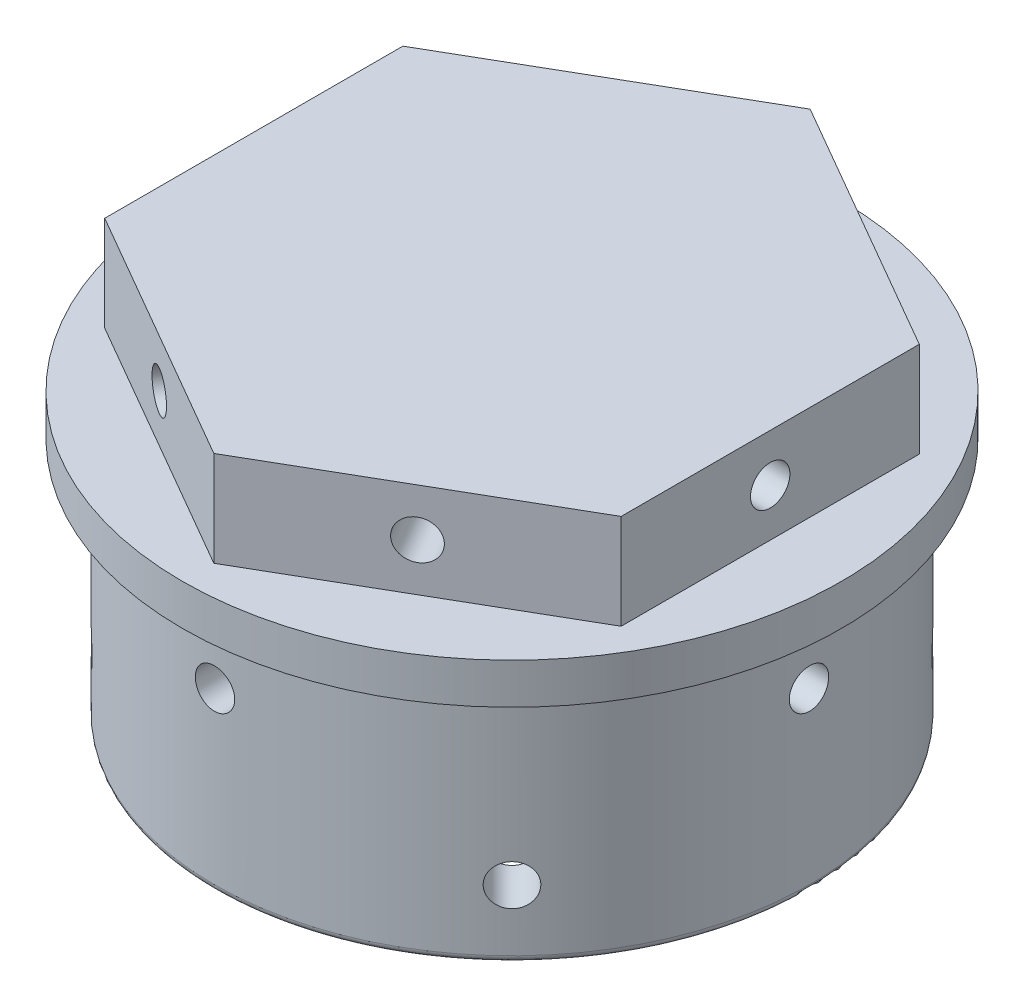
from build123d import *

# Parameters (mm, degrees)
SKETCH_1_R                = 19
SKETCH_1_R_2              = 1.45
SKETCH_1_R_3              = 2
EXTRUDE_1_DEPTH           = 12
SKETCH_2_R                = 1.45
SKETCH_2_R_2              = 2
EXTRUDE_2_DEPTH           = 7
SKETCH_3_R                = 1.45
CUT_EXTRUDE_1_DEPTH       = 48.5
SKETCH_4_R                = 1.45
CUT_EXTRUDE_2_DEPTH       = 48.5
SKETCH_5_R                = 1.45
CUT_EXTRUDE_3_DEPTH       = 39
SKETCH_8_R                = 24
CUT_EXTRUDE_6_DEPTH       = 5
SKETCH_10_R               = 24.25
EXTRUDE_3_DEPTH           = 3
SKETCH_11_R               = 21.9
EXTRUDE_4_DEPTH           = 18
CUT_EXTRUDE_7_DEPTH       = 18
SKETCH_13_R               = 1.45
CUT_EXTRUDE_8_DEPTH       = 43.25
CUT_EXTRUDE_8_DEPTH_BACK  = 7.25
SKETCH_14_R               = 1.45
CUT_EXTRUDE_9_DEPTH       = 53.294678888
CUT_EXTRUDE_9_DEPTH_BACK  = 17.294678888
SKETCH_15_R               = 1.45
CUT_EXTRUDE_10_DEPTH      = 43.25
CUT_EXTRUDE_10_DEPTH_BACK = 7.25
SKETCH_16_R               = 1.5
CUT_EXTRUDE_11_DEPTH      = 53.294678888
CUT_EXTRUDE_11_DEPTH_BACK = 17.294678888
FILLET_1_R                = 0.5
FILLET_2_R                = 2
SKETCH_17_R               = 1.45
SKETCH_17_R_2             = 2
SKETCH_17_R_3             = 2.272593427
EXTRUDE_5_DEPTH           = 9


with BuildPart() as part:
    # 草图1 → 凸台-拉伸1 (new body)
    with BuildSketch(Plane(origin=(0, 0, 0), x_dir=(1, 0, 0), z_dir=(0, 1, 0))):
        Circle(SKETCH_1_R)
        with Locations((0, 13.5)):
            Circle(SKETCH_1_R_2, mode=Mode.SUBTRACT)
        with Locations((-11.691342951, -6.75)):
            Circle(SKETCH_1_R_2, mode=Mode.SUBTRACT)
        with Locations((11.691342951, -6.75)):
            Circle(SKETCH_1_R_2, mode=Mode.SUBTRACT)
        with Locations((-10.522208656, 6.075)):
            Circle(SKETCH_1_R_3, mode=Mode.SUBTRACT)
        with Locations((0, -12.15)):
            Circle(SKETCH_1_R_3, mode=Mode.SUBTRACT)
        with Locations((10.522208656, 6.075)):
            Circle(SKETCH_1_R_3, mode=Mode.SUBTRACT)
    extrude(amount=EXTRUDE_1_DEPTH)

    # 草图2 → 凸台-拉伸2 (add)
    with BuildSketch(Plane(origin=(0, 12, 0), x_dir=(1, 0, 0), z_dir=(0, 1, 0))):
        Polygon((0, 21.939310229), (-19, 10.969655115), (-19, -10.969655115), (0, -21.939310229), (19, -10.969655115), (19, 10.969655115), align=None)
        with Locations((0, 13.5)):
            Circle(SKETCH_2_R, mode=Mode.SUBTRACT)
        with Locations((-10.522208656, 6.075)):
            Circle(SKETCH_2_R_2, mode=Mode.SUBTRACT)
        with Locations((10.522208656, 6.075)):
            Circle(SKETCH_2_R_2, mode=Mode.SUBTRACT)
        with Locations((-11.691342951, -6.75)):
            Circle(SKETCH_2_R, mode=Mode.SUBTRACT)
        with Locations((0, -12.15)):
            Circle(SKETCH_2_R_2, mode=Mode.SUBTRACT)
        with Locations((11.691342951, -6.75)):
            Circle(SKETCH_2_R, mode=Mode.SUBTRACT)
    extrude(amount=-EXTRUDE_2_DEPTH)

    # 草图3 → 切除-拉伸1 (cut, through all)
    with BuildSketch(Plane(origin=(9.5, 0, 16.454482672), x_dir=(0.866025404, 0, -0.5), z_dir=(0.5, 0, 0.866025404))):
        with Locations((0, 8.5)):
            Circle(SKETCH_3_R)
    extrude(amount=-CUT_EXTRUDE_1_DEPTH, mode=Mode.SUBTRACT)

    # 草图4 → 切除-拉伸2 (cut, through all)
    with BuildSketch(Plane(origin=(-9.5, 0, 16.454482672), x_dir=(0.866025404, 0, 0.5), z_dir=(-0.5, 0, 0.866025404))):
        with Locations((0, 8.5)):
            Circle(SKETCH_4_R)
    extrude(amount=-CUT_EXTRUDE_2_DEPTH, mode=Mode.SUBTRACT)

    # 草图5 → 切除-拉伸3 (cut, through all)
    with BuildSketch(Plane.ZY.offset(19)):
        with Locations((0, 8.5)):
            Circle(SKETCH_5_R)
    extrude(amount=-CUT_EXTRUDE_3_DEPTH, mode=Mode.SUBTRACT)

    # 草图8 → 切除-拉伸6 (cut)
    with BuildSketch(Plane.XZ):
        Circle(SKETCH_8_R)
    extrude(amount=-CUT_EXTRUDE_6_DEPTH, mode=Mode.SUBTRACT)

    # 草图10 → 凸台-拉伸3 (add)
    with BuildSketch(Plane.XZ.offset(-5)):
        Circle(SKETCH_10_R)
    extrude(amount=EXTRUDE_3_DEPTH)

    # 草图11 → 凸台-拉伸4 (add)
    with BuildSketch(Plane.XZ.offset(-2)):
        Circle(SKETCH_11_R)
    extrude(amount=EXTRUDE_4_DEPTH)

    # 草图12 → 切除-拉伸7 (cut)
    with BuildSketch(Plane.XZ.offset(16)):
        with BuildLine():
            Line((-15.656854249, -9.798989873), (-9.798989873, -15.656854249))
            ThreePointArc((-9.798989873, -15.656854249), (-7.203603083, -17.39103626), (-4.142135624, -18))
            Line((-4.142135624, -18), (4.142135624, -18))
            ThreePointArc((4.142135624, -18), (7.203603083, -17.39103626), (9.798989873, -15.656854249))
            Line((9.798989873, -15.656854249), (15.656854249, -9.798989873))
            ThreePointArc((15.656854249, -9.798989873), (17.39103626, -7.203603083), (18, -4.142135624))
            Line((18, -4.142135624), (18, 4.142135624))
            ThreePointArc((18, 4.142135624), (17.39103626, 7.203603083), (15.656854249, 9.798989873))
            Line((15.656854249, 9.798989873), (9.798989873, 15.656854249))
            ThreePointArc((9.798989873, 15.656854249), (7.203603083, 17.39103626), (4.142135624, 18))
            Line((4.142135624, 18), (-4.142135624, 18))
            ThreePointArc((-4.142135624, 18), (-7.203603083, 17.39103626), (-9.798989873, 15.656854249))
            Line((-9.798989873, 15.656854249), (-15.656854249, 9.798989873))
            ThreePointArc((-15.656854249, 9.798989873), (-17.39103626, 7.203603083), (-18, 4.142135624))
            Line((-18, 4.142135624), (-18, -4.142135624))
            ThreePointArc((-18, -4.142135624), (-17.39103626, -7.203603083), (-15.656854249, -9.798989873))
        make_face()
    extrude(amount=-CUT_EXTRUDE_7_DEPTH, mode=Mode.SUBTRACT)

    # 草图13 → 切除-拉伸8 (cut, two sides)
    with BuildSketch(Plane.ZY.offset(-18)) as cut_extrude_8_sk:
        with Locations((0, -3)):
            Circle(SKETCH_13_R)
    extrude(amount=CUT_EXTRUDE_8_DEPTH, mode=Mode.SUBTRACT)
    extrude(cut_extrude_8_sk.sketch, amount=-CUT_EXTRUDE_8_DEPTH_BACK, mode=Mode.SUBTRACT)

    # 草图14 → 切除-拉伸9 (cut, two sides)
    with BuildSketch(Plane(origin=(12.727922061, 0, -12.727922061), x_dir=(0.707106781, 0, 0.707106781), z_dir=(-0.707106781, 0, 0.707106781))) as cut_extrude_9_sk:
        with Locations((0, -11)):
            Circle(SKETCH_14_R)
    extrude(amount=CUT_EXTRUDE_9_DEPTH, mode=Mode.SUBTRACT)
    extrude(cut_extrude_9_sk.sketch, amount=-CUT_EXTRUDE_9_DEPTH_BACK, mode=Mode.SUBTRACT)

    # 草图15 → 切除-拉伸10 (cut, two sides)
    with BuildSketch(Plane.XY.offset(-18)) as cut_extrude_10_sk:
        with Locations((0, -3)):
            Circle(SKETCH_15_R)
    extrude(amount=CUT_EXTRUDE_10_DEPTH, mode=Mode.SUBTRACT)
    extrude(cut_extrude_10_sk.sketch, amount=-CUT_EXTRUDE_10_DEPTH_BACK, mode=Mode.SUBTRACT)

    # 草图16 → 切除-拉伸11 (cut, two sides)
    with BuildSketch(Plane(origin=(-12.727922061, 0, -12.727922061), x_dir=(0.707106781, 0, -0.707106781), z_dir=(0.707106781, 0, 0.707106781))) as cut_extrude_11_sk:
        with Locations((0, -11)):
            Circle(SKETCH_16_R)
    extrude(amount=CUT_EXTRUDE_11_DEPTH, mode=Mode.SUBTRACT)
    extrude(cut_extrude_11_sk.sketch, amount=-CUT_EXTRUDE_11_DEPTH_BACK, mode=Mode.SUBTRACT)

    # 圆角1
    fillet_1_edges = [part.edges().sort_by_distance(p)[0] for p in [
        (-21.9, -16, 0),
        (-7.203603083, -16, 17.39103626),
        (-12.727922061, -16, 12.727922061),
        (-17.39103626, -16, 7.203603083),
        (-18, -16, 0),
        (-17.39103626, -16, -7.203603083),
        (-12.727922061, -16, -12.727922061),
        (-7.203603083, -16, -17.39103626),
        (0, -16, -18),
        (7.203603083, -16, -17.39103626),
        (12.727922061, -16, -12.727922061),
        (17.39103626, -16, -7.203603083),
        (18, -16, 0),
        (17.39103626, -16, 7.203603083),
        (12.727922061, -16, 12.727922061),
        (7.203603083, -16, 17.39103626),
        (0, -16, 18),
    ]]
    fillet(fillet_1_edges, radius=FILLET_1_R)

    # 圆角2
    fillet_2_edges = [part.edges().sort_by_distance(p)[0] for p in [
        (-7.203603083, 2, 17.39103626),
        (0, 2, 18),
        (7.203603083, 2, 17.39103626),
        (12.727922061, 2, 12.727922061),
        (17.39103626, 2, 7.203603083),
        (18, 2, 0),
        (17.39103626, 2, -7.203603083),
        (12.727922061, 2, -12.727922061),
        (7.203603083, 2, -17.39103626),
        (0, 2, -18),
        (-7.203603083, 2, -17.39103626),
        (-12.727922061, 2, -12.727922061),
        (-17.39103626, 2, -7.203603083),
        (-18, 2, 0),
        (-17.39103626, 2, 7.203603083),
        (-12.727922061, 2, 12.727922061),
    ]]
    fillet(fillet_2_edges, radius=FILLET_2_R)

    # 草图17 → 凸台-拉伸5 (add)
    with BuildSketch(Plane(origin=(0, 12, 0), x_dir=(1, 0, 0), z_dir=(0, 1, 0))):
        with Locations((0, 13.5)):
            Circle(SKETCH_17_R)
        with Locations((10.522208656, 6.075)):
            Circle(SKETCH_17_R_2)
        with Locations((11.691342951, -6.75)):
            Circle(SKETCH_17_R)
        with Locations((0, -12.15)):
            Circle(SKETCH_17_R_2)
        with Locations((-11.691342951, -6.75)):
            Circle(SKETCH_17_R)
        with Locations((-10.522208656, 6.075)):
            Circle(SKETCH_17_R_3)
    extrude(amount=-EXTRUDE_5_DEPTH)


solid = part.part
